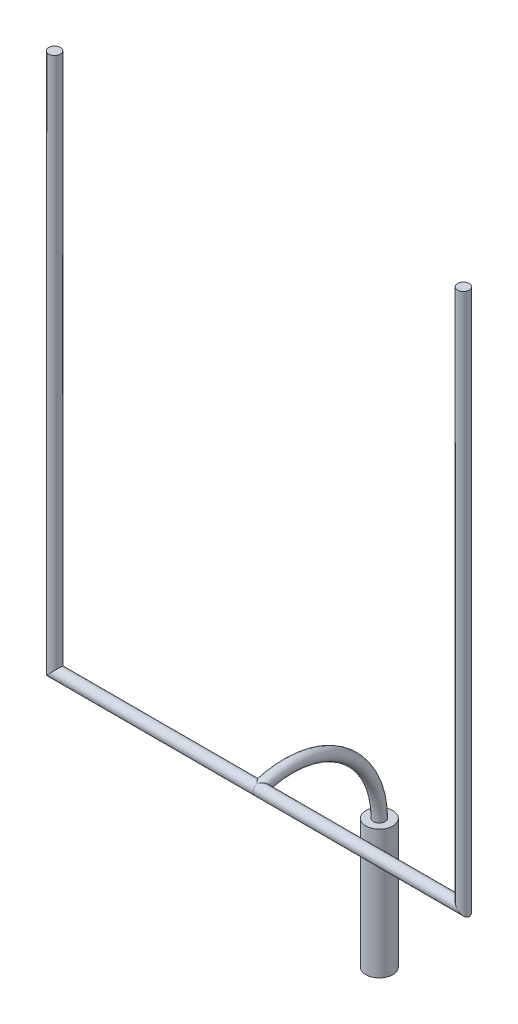
from build123d import *

# Parameters (mm, degrees)
SWEEP4_PROFILE_R    = 82.55
SWEEP6_PROFILE_R    = 82.55
SKETCH69_R          = 190.5
BOSS_EXTRUDE3_DEPTH = 1828.8


with BuildPart() as part:
    # Sweep4: sweep along a path in Sketch1
    with BuildLine(Plane.XY) as sweep4_path:
        Line((2901.95, 7620), (2901.95, 0))
        Line((2901.95, 0), (0, 0))
        Line((0, 0), (-2901.95, 0))
        Line((-2901.95, 0), (-2901.95, 7620))
    # Sweep4 profile (on start of the path) → Sweep4 (sweep)
    with BuildSketch(Plane(origin=(2901.95, 7620, 0), x_dir=(0, 0, -1), z_dir=(0, -1, 0))):
        Circle(SWEEP4_PROFILE_R)
    sweep(path=sweep4_path.line, transition=Transition.RIGHT)

    # Sweep6: sweep along a path in Sketch23
    with BuildLine(Plane(origin=(0, 0, 0), x_dir=(0, 0, -1), z_dir=(1, 0, 0))) as sweep6_path:
        Line((1708.15, -3048), (1708.15, -1219.2))
        ThreePointArc((1708.15, -1219.2), (1167.92168471, -169.887717777), (0, 0))
    # Sweep6 profile (on start of the path) → Sweep6 (sweep)
    with BuildSketch(Plane(origin=(0, -3048, -1708.15), x_dir=(0, 0, 1), z_dir=(0, 1, 0))):
        Circle(SWEEP6_PROFILE_R)
    sweep(path=sweep6_path.line)

    # Sketch69 → Boss-Extrude3 (add)
    with BuildSketch(Plane.XZ.offset(3048)):
        with Locations((0, -1708.15)):
            Circle(SKETCH69_R)
    extrude(amount=-BOSS_EXTRUDE3_DEPTH)


solid = part.part
